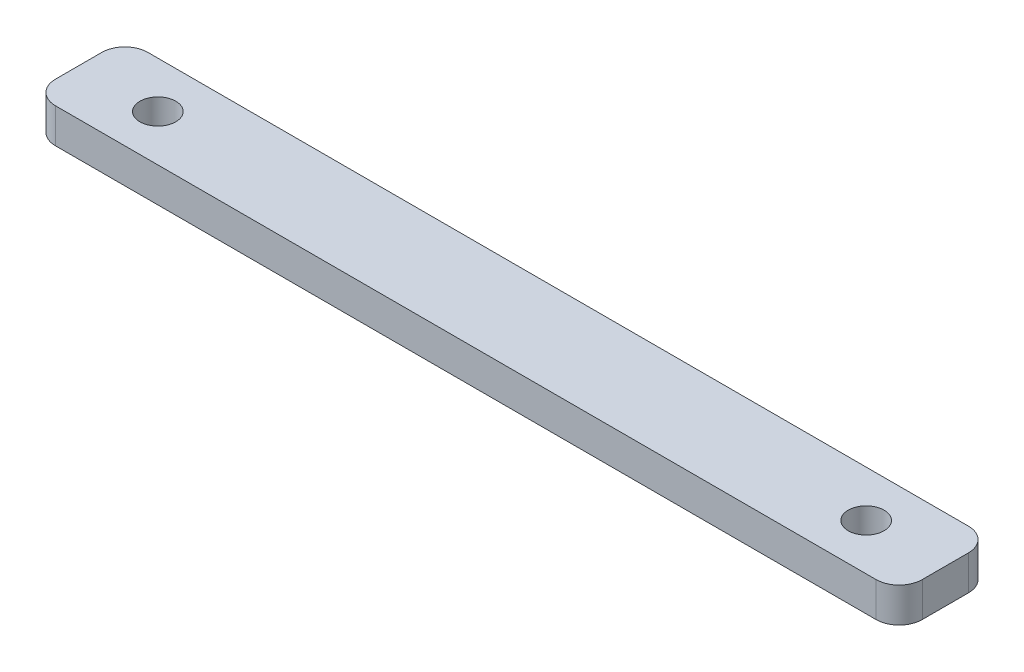
from build123d import *

# Parameters (mm, degrees)
SKETCH_1_W      = 75
SKETCH_1_H      = 8
SKETCH_1_R      = 1.55
EXTRUDE_1_DEPTH = 3
FILLET_1_R      = 2


with BuildPart() as part:
    # 草图1 → 凸台-拉伸1 (new body)
    with BuildSketch(Plane(origin=(0, 0, 0), x_dir=(1, 0, 0), z_dir=(0, 1, 0))):
        Rectangle(SKETCH_1_W, SKETCH_1_H)
        with Locations((-30.645, 0)):
            Circle(SKETCH_1_R, mode=Mode.SUBTRACT)
        with Locations((30.645, 0)):
            Circle(SKETCH_1_R, mode=Mode.SUBTRACT)
    extrude(amount=EXTRUDE_1_DEPTH)

    # 圆角1
    fillet_1_edges = [part.edges().sort_by_distance(p)[0] for p in [
        (-37.5, 1.5, -4),
        (37.5, 1.5, -4),
        (37.5, 1.5, 4),
        (-37.5, 1.5, 4),
    ]]
    fillet(fillet_1_edges, radius=FILLET_1_R)


solid = part.part
